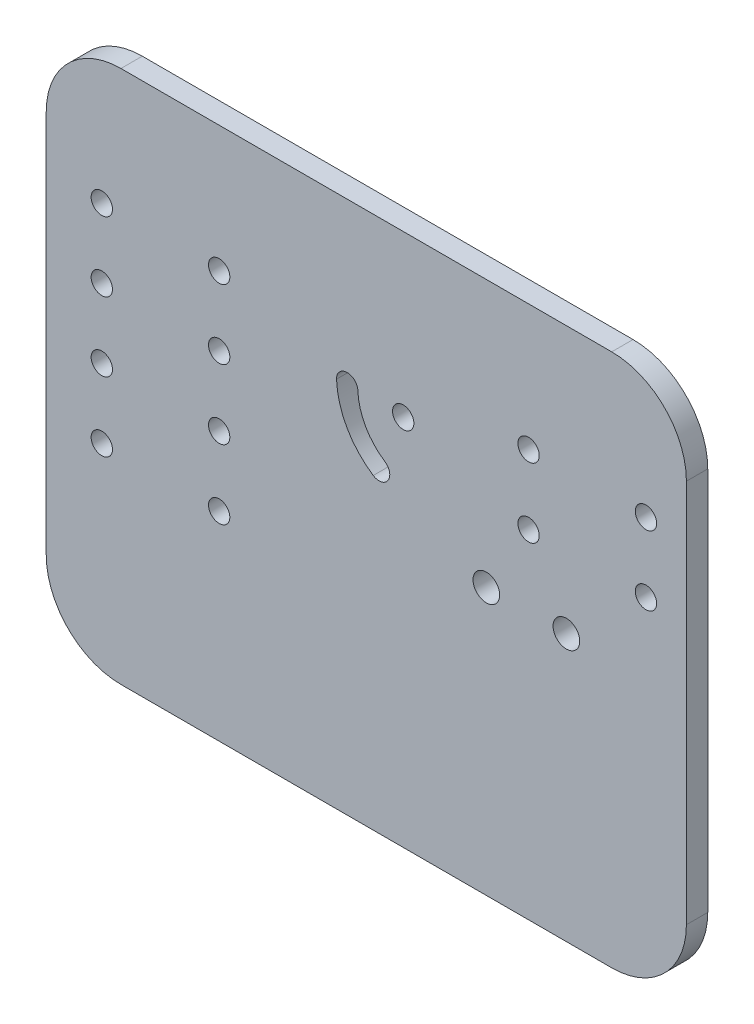
from build123d import *

# Parameters (mm, degrees)
SKETCH_1_W          = 120
SKETCH_1_H          = 100
EXTRUDE_1_DEPTH     = 4
FILLET_1_R          = 14
SKETCH_7_R          = 2.5
CUT_EXTRUDE_2_DEPTH = 5
SKETCH_14_R         = 2
CUT_EXTRUDE_3_DEPTH = 5


with BuildPart() as part:
    # 草图1 → 凸台-拉伸1 (new body)
    with BuildSketch(Plane.XY):
        with Locations((7.34439834, -11.161825726)):
            Rectangle(SKETCH_1_W, SKETCH_1_H)
    extrude(amount=EXTRUDE_1_DEPTH)

    # 圆角1
    fillet_1_edges = [part.edges().sort_by_distance(p)[0] for p in [
        (-52.65560166, 38.838174274, 2),
        (67.34439834, 38.838174274, 2),
        (67.34439834, -61.161825726, 2),
        (-52.65560166, -61.161825726, 2),
    ]]
    fillet(fillet_1_edges, radius=FILLET_1_R)

    # 草图7 → 切除-拉伸2 (cut, through all)
    with BuildSketch(Plane(origin=(0, 0, 0), x_dir=(-1, 0, 0), z_dir=(0, 0, -1))):
        with Locations((-44.84439834, -11.161825726)):
            Circle(SKETCH_7_R)
        with Locations((-29.84439834, -11.161825726)):
            Circle(SKETCH_7_R)
    extrude(amount=-CUT_EXTRUDE_2_DEPTH, mode=Mode.SUBTRACT)

    # 草图14 → 切除-拉伸3 (cut, through all)
    with BuildSketch(Plane(origin=(0, 0, 0), x_dir=(-1, 0, 0), z_dir=(0, 0, -1))):
        with Locations((42.240931861, -23.815848238)):
            Circle(SKETCH_14_R)
        with Locations((20.240931861, -23.815848238)):
            Circle(SKETCH_14_R)
        with Locations((42.240931861, -10.815848238)):
            Circle(SKETCH_14_R)
        with Locations((20.240931861, -10.815848238)):
            Circle(SKETCH_14_R)
        with Locations((42.240931861, 2.184151762)):
            Circle(SKETCH_14_R)
        with Locations((42.240931861, 15.184151762)):
            Circle(SKETCH_14_R)
        with Locations((20.240931861, 2.184151762)):
            Circle(SKETCH_14_R)
        with Locations((20.240931861, 15.184151762)):
            Circle(SKETCH_14_R)
        with Locations((-14.259068139, 8.684151762)):
            Circle(SKETCH_14_R)
        with Locations((-37.759068139, 2.184151762)):
            Circle(SKETCH_14_R)
        with Locations((-59.759068139, 2.184151762)):
            Circle(SKETCH_14_R)
        with Locations((-59.759068139, 15.184151762)):
            Circle(SKETCH_14_R)
        with Locations((-37.759068139, 15.184151762)):
            Circle(SKETCH_14_R)
        with BuildLine():
            ThreePointArc((-1.760462288, 8.609488161), (-3.684404538, 10.682757613), (-5.75767399, 8.758815364))
            ThreePointArc((-5.75767399, 8.758815364), (-7.203940461, 3.643892075), (-10.83494306, -0.238110898))
            ThreePointArc((-10.83494306, -0.238110898), (-11.410230768, -3.007414792), (-8.640926875, -3.5827025))
            ThreePointArc((-8.640926875, -3.5827025), (-3.720371267, 1.677996434), (-1.760462288, 8.609488161))
        make_face()
    extrude(amount=-CUT_EXTRUDE_3_DEPTH, mode=Mode.SUBTRACT)


solid = part.part
